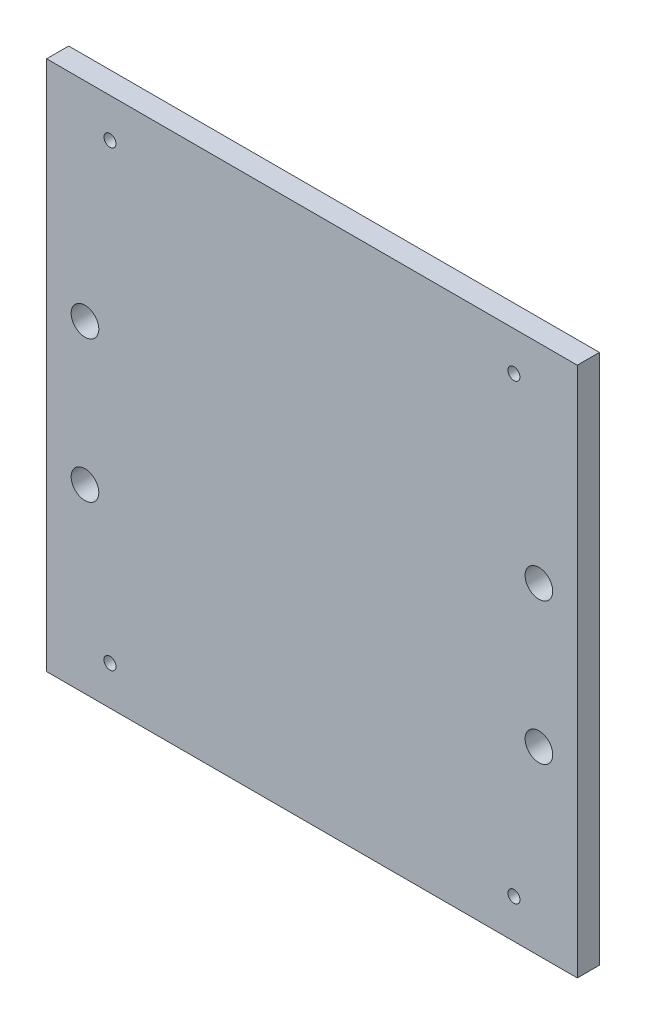
from build123d import *

# Parameters (mm, degrees)
SKETCH1_W                          = 152.4
SKETCH1_H                          = 152.4
BOSS_EXTRUDE1_DEPTH                = 6.35
F_5_16_0_3125_DIAMETER_HOLE1_D     = 7.9375
F_5_16_0_3125_DIAMETER_HOLE1_DEPTH = 6.35
F_8_32_TAPPED_HOLE1_D              = 3.4544
F_8_32_TAPPED_HOLE1_DEPTH          = 6.35


with BuildPart() as part:
    # Sketch1 → Boss-Extrude1 (new body)
    with BuildSketch(Plane.XY):
        with Locations((0, 113)):
            Rectangle(SKETCH1_W, SKETCH1_H)
    extrude(amount=BOSS_EXTRUDE1_DEPTH)

    # 5/16 (0.3125) Diameter Hole1
    with Locations(Plane(origin=(0, 0, 0), x_dir=(-1, 0, 0), z_dir=(0, 0, -1))):
        with Locations((65.1764, 88.807), (65.1764, 129.447), (-65.1764, 129.447), (-65.1764, 88.807)):
            Hole(F_5_16_0_3125_DIAMETER_HOLE1_D / 2, depth=F_5_16_0_3125_DIAMETER_HOLE1_DEPTH)

    # #8-32 Tapped Hole1
    with Locations(Plane(origin=(0, 0, 0), x_dir=(-1, 0, 0), z_dir=(0, 0, -1))):
        with Locations((-58, 178), (58, 178), (58, 48), (-58, 48)):
            Hole(F_8_32_TAPPED_HOLE1_D / 2, depth=F_8_32_TAPPED_HOLE1_DEPTH)


solid = part.part
